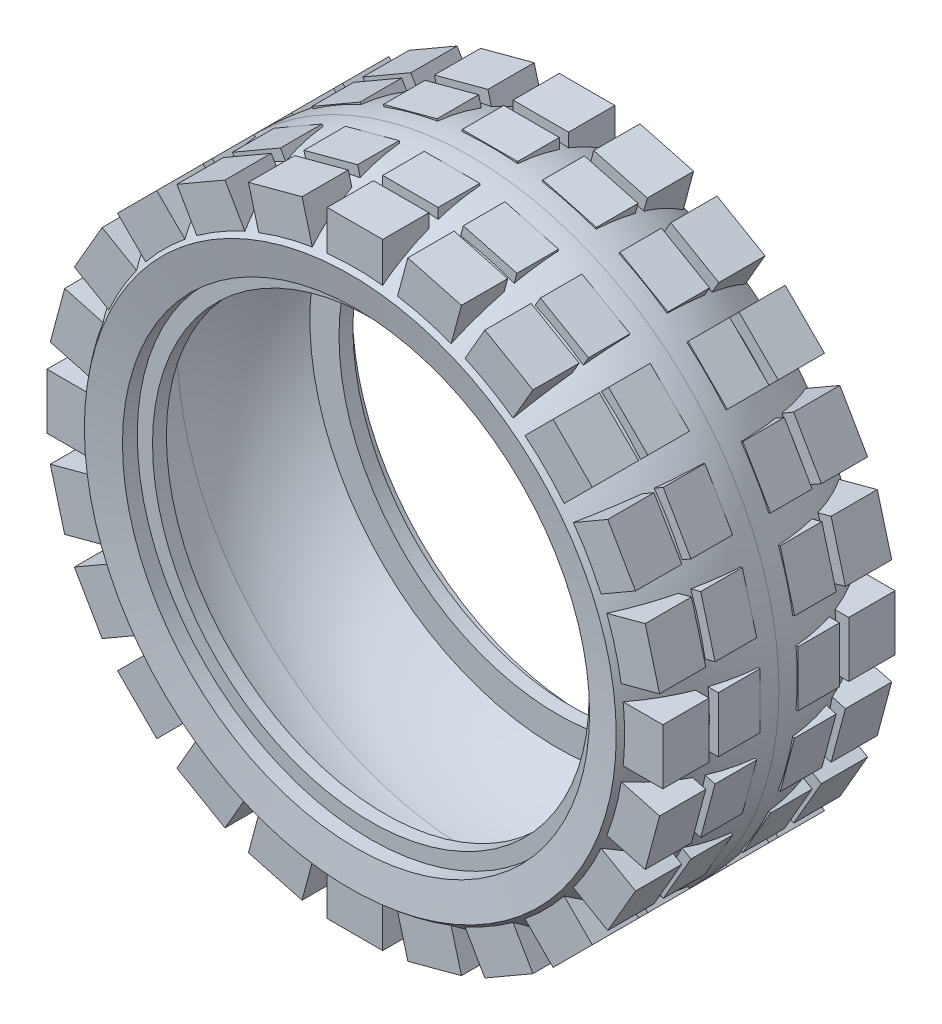
from build123d import *

# Parameters (mm, degrees)
BOSS_EXTRUDE1_REACH = 608.441
SKETCH2_W           = 48
SKETCH2_H           = 36
SKETCH2_H_2         = 40
CIRPATTERN1_COUNT   = 24


with BuildPart() as part:
    # Sketch1 → Revolve1 (revolve)
    with BuildSketch(Plane(origin=(0, 0, 0), x_dir=(0, 0, -1), z_dir=(1, 0, 0)), mode=Mode.PRIVATE) as revolve1_sk:
        with BuildLine():
            Line((-94.37715546, 230), (-89.44, 202))
            Line((-89.44, 202), (-76.64, 202))
            Line((-76.64, 202), (-76.64, 188.8))
            Line((-76.64, 188.8), (-64.64, 188.8))
            Line((-64.64, 188.8), (-64.64, 214))
            Line((-64.64, 214), (-79.370804426, 214))
            Line((-79.370804426, 214), (-80.781420272, 222))
            ThreePointArc((-80.781420272, 222), (-38.54898213, 247.032475188), (10, 254.3263068))
            ThreePointArc((10, 254.3263068), (58.54898213, 247.032475188), (100.781420272, 222))
            Line((100.781420272, 222), (99.370804426, 214))
            Line((99.370804426, 214), (84.64, 214))
            Line((84.64, 214), (84.64, 188.8))
            Line((84.64, 188.8), (96.64, 188.8))
            Line((96.64, 188.8), (96.64, 202))
            Line((96.64, 202), (109.44, 202))
            Line((109.44, 202), (114.37715546, 230))
            ThreePointArc((114.37715546, 230), (65.424627254, 257.461363815), (10, 266.3263068))
            ThreePointArc((10, 266.3263068), (-45.424627254, 257.461363815), (-94.37715546, 230))
        make_face()
    revolve(revolve1_sk.sketch.rotate(Axis((0, 0, 0), (0, 0, -1)), 90), axis=Axis((0, 0, 0), (0, 0, -1)))

    # Sketch2 → Boss-Extrude1 (add, up to next)
    with BuildSketch(Plane(origin=(0, 266.3263068, 0), x_dir=(-1, 0, 0), z_dir=(0, -1, 0)), mode=Mode.PRIVATE) as boss_extrude1_sk1:
        with Locations((0, 44.37715546)):
            Rectangle(SKETCH2_W, SKETCH2_H)
    boss_extrude1_tool1 = extrude(boss_extrude1_sk1.sketch, amount=BOSS_EXTRUDE1_REACH, mode=Mode.PRIVATE) - part.part
    # Sketch2 → Boss-Extrude1 (add, up to next)
    with BuildSketch(Plane(origin=(0, 266.3263068, 0), x_dir=(-1, 0, 0), z_dir=(0, -1, 0)), mode=Mode.PRIVATE) as boss_extrude1_sk2:
        with Locations((0, 90.37715546)):
            Rectangle(SKETCH2_W, SKETCH2_H_2)
    boss_extrude1_tool2 = extrude(boss_extrude1_sk2.sketch, amount=BOSS_EXTRUDE1_REACH, mode=Mode.PRIVATE) - part.part
    # Sketch2 → Boss-Extrude1 (add, up to next)
    with BuildSketch(Plane(origin=(0, 266.3263068, 0), x_dir=(-1, 0, 0), z_dir=(0, -1, 0)), mode=Mode.PRIVATE) as boss_extrude1_sk3:
        with Locations((0, -24.37715546)):
            Rectangle(SKETCH2_W, SKETCH2_H)
    boss_extrude1_tool3 = extrude(boss_extrude1_sk3.sketch, amount=BOSS_EXTRUDE1_REACH, mode=Mode.PRIVATE) - part.part
    # Sketch2 → Boss-Extrude1 (add, up to next)
    with BuildSketch(Plane(origin=(0, 266.3263068, 0), x_dir=(-1, 0, 0), z_dir=(0, -1, 0)), mode=Mode.PRIVATE) as boss_extrude1_sk4:
        with Locations((0, -70.37715546)):
            Rectangle(SKETCH2_W, SKETCH2_H_2)
    boss_extrude1_tool4 = extrude(boss_extrude1_sk4.sketch, amount=BOSS_EXTRUDE1_REACH, mode=Mode.PRIVATE) - part.part
    boss_extrude1_1 = boss_extrude1_tool1.solids().sort_by_distance((0, 266.326307, -44.377155))[0]
    add(boss_extrude1_1)
    boss_extrude1_2 = boss_extrude1_tool2.solids().sort_by_distance((0, 266.326307, -90.377155))[0]
    add(boss_extrude1_2)
    boss_extrude1_3 = boss_extrude1_tool3.solids().sort_by_distance((0, 266.326307, 24.377155))[0]
    add(boss_extrude1_3)
    boss_extrude1_4 = boss_extrude1_tool4.solids().sort_by_distance((0, 266.326307, 70.377155))[0]
    add(boss_extrude1_4)
    boss_extrude1 = boss_extrude1_1 + boss_extrude1_2 + boss_extrude1_3 + boss_extrude1_4  # Boss-Extrude1 as one shape, for the pattern or mirror that repeats it

    # CirPattern1: Boss-Extrude1 ×24 about axis
    cirpattern1_axis = Axis((0, 0, 0), (0, 0, 1))
    for i in range(1, CIRPATTERN1_COUNT):
        add(boss_extrude1.rotate(cirpattern1_axis, i * 360 / CIRPATTERN1_COUNT))


solid = part.part
